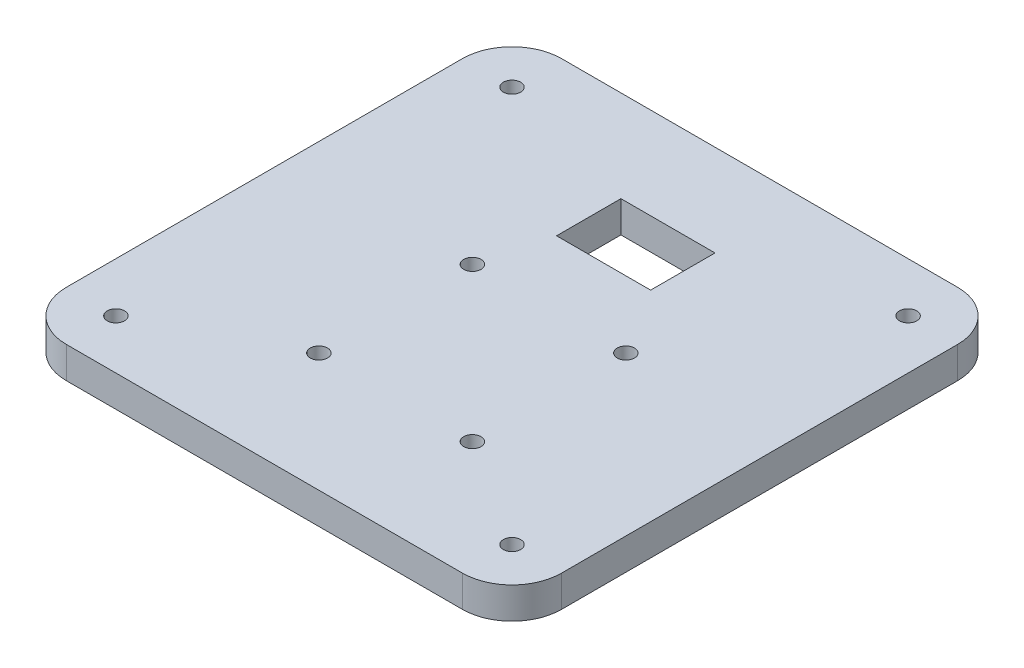
from build123d import *

# Parameters (mm, degrees)
SKETCH2_W                 = 100
SKETCH2_H                 = 100
BOSS_EXTRUDE1_DEPTH       = 6.35
SKETCH3_R                 = 1.75
CUT_EXTRUDE1_DEPTH        = 7.35
LPATTERN1_COUNT           = 2
LPATTERN1_PITCH           = 80
LPATTERN2_COUNT           = 2
LPATTERN2_PITCH           = 80
LPATTERN2_COPY_1_SKETCH_R = 1.75
LPATTERN2_COPY_1_DEPTH    = 7.35
SKETCH8_R                 = 1.75
CUT_EXTRUDE2_DEPTH        = 7.35
LPATTERN3_COUNT           = 2
LPATTERN3_PITCH           = 31
LPATTERN4_COUNT           = 2
LPATTERN4_PITCH           = 31
LPATTERN4_COPY_1_SKETCH_R = 1.75
LPATTERN4_COPY_1_DEPTH    = 7.35
SKETCH9_W                 = 19
SKETCH9_H                 = 13
CUT_EXTRUDE3_DEPTH        = 7.35
FILLET1_R                 = 10


with BuildPart() as part:
    # Sketch2 → Boss-Extrude1 (new body)
    with BuildSketch(Plane(origin=(0, 0, 0), x_dir=(1, 0, 0), z_dir=(0, 1, 0))):
        Rectangle(SKETCH2_W, SKETCH2_H)
    extrude(amount=BOSS_EXTRUDE1_DEPTH)

    # Sketch3 → Cut-Extrude1 (cut, through all)
    with BuildSketch(Plane.XZ):
        with Locations((-40, -40)):
            Circle(SKETCH3_R)
    cut_extrude1 = extrude(amount=-CUT_EXTRUDE1_DEPTH, mode=Mode.SUBTRACT)

    # LPattern1: Cut-Extrude1 ×2
    with Locations(*[(0, 0, i * LPATTERN1_PITCH) for i in range(1, LPATTERN1_COUNT)]):
        add(cut_extrude1, mode=Mode.SUBTRACT)

    # LPattern2: Cut-Extrude1 ×2
    with Locations(*[(i * LPATTERN2_PITCH, 0, 0) for i in range(1, LPATTERN2_COUNT)]):
        add(cut_extrude1, mode=Mode.SUBTRACT)

    # LPattern2 copy 1 sketch → LPattern2 copy 1 (cut, through all)
    with BuildSketch(Plane(origin=(80, 0, 80), x_dir=(1, 0, 0), z_dir=(0, -1, 0))):
        with Locations((-40, -40)):
            Circle(LPATTERN2_COPY_1_SKETCH_R)
    extrude(amount=-LPATTERN2_COPY_1_DEPTH, mode=Mode.SUBTRACT)

    # Sketch8 → Cut-Extrude2 (cut, through all)
    with BuildSketch(Plane.XZ):
        with Locations((18, -5)):
            Circle(SKETCH8_R)
    cut_extrude2 = extrude(amount=-CUT_EXTRUDE2_DEPTH, mode=Mode.SUBTRACT)

    # LPattern3: Cut-Extrude2 ×2
    with Locations(*[(0, 0, i * LPATTERN3_PITCH) for i in range(1, LPATTERN3_COUNT)]):
        add(cut_extrude2, mode=Mode.SUBTRACT)

    # LPattern4: Cut-Extrude2 ×2
    with Locations(*[(-i * LPATTERN4_PITCH, 0, 0) for i in range(1, LPATTERN4_COUNT)]):
        add(cut_extrude2, mode=Mode.SUBTRACT)

    # LPattern4 copy 1 sketch → LPattern4 copy 1 (cut, through all)
    with BuildSketch(Plane(origin=(-31, 0, 31), x_dir=(1, 0, 0), z_dir=(0, -1, 0))):
        with Locations((18, -5)):
            Circle(LPATTERN4_COPY_1_SKETCH_R)
    extrude(amount=-LPATTERN4_COPY_1_DEPTH, mode=Mode.SUBTRACT)

    # Sketch9 → Cut-Extrude3 (cut, through all)
    with BuildSketch(Plane.XZ):
        with Locations((0, -25)):
            Rectangle(SKETCH9_W, SKETCH9_H)
    extrude(amount=-CUT_EXTRUDE3_DEPTH, mode=Mode.SUBTRACT)

    # Fillet1
    fillet1_edges = [part.edges().sort_by_distance(p)[0] for p in [
        (-50, 3.175, -50),
        (-50, 3.175, 50),
        (50, 3.175, 50),
        (50, 3.175, -50),
    ]]
    fillet(fillet1_edges, radius=FILLET1_R)


solid = part.part
